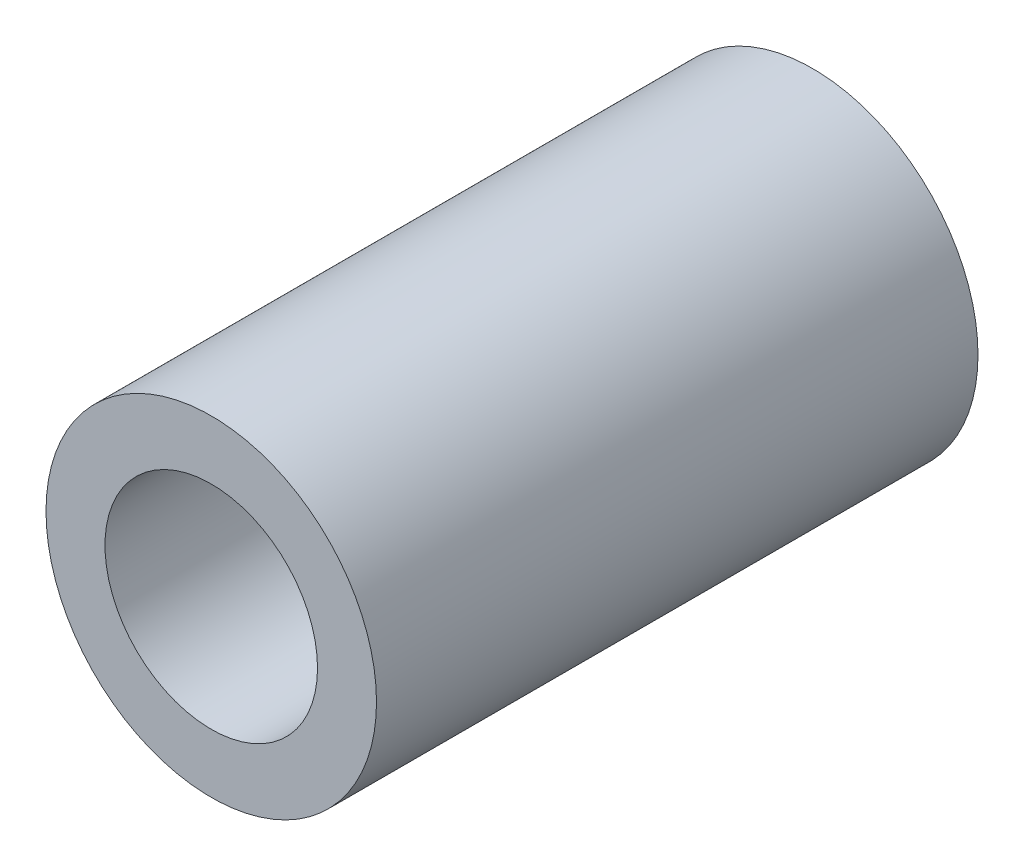
from build123d import *

# Parameters (mm, degrees)
CROQUIS1_R              = 15.55
CROQUIS1_R_2            = 10
SALIENTE_EXTRUIR1_DEPTH = 56.6


with BuildPart() as part:
    # Croquis1 → Saliente-Extruir1 (new body)
    with BuildSketch(Plane.XY):
        Circle(CROQUIS1_R)
        Circle(CROQUIS1_R_2, mode=Mode.SUBTRACT)
    extrude(amount=SALIENTE_EXTRUIR1_DEPTH)


solid = part.part
